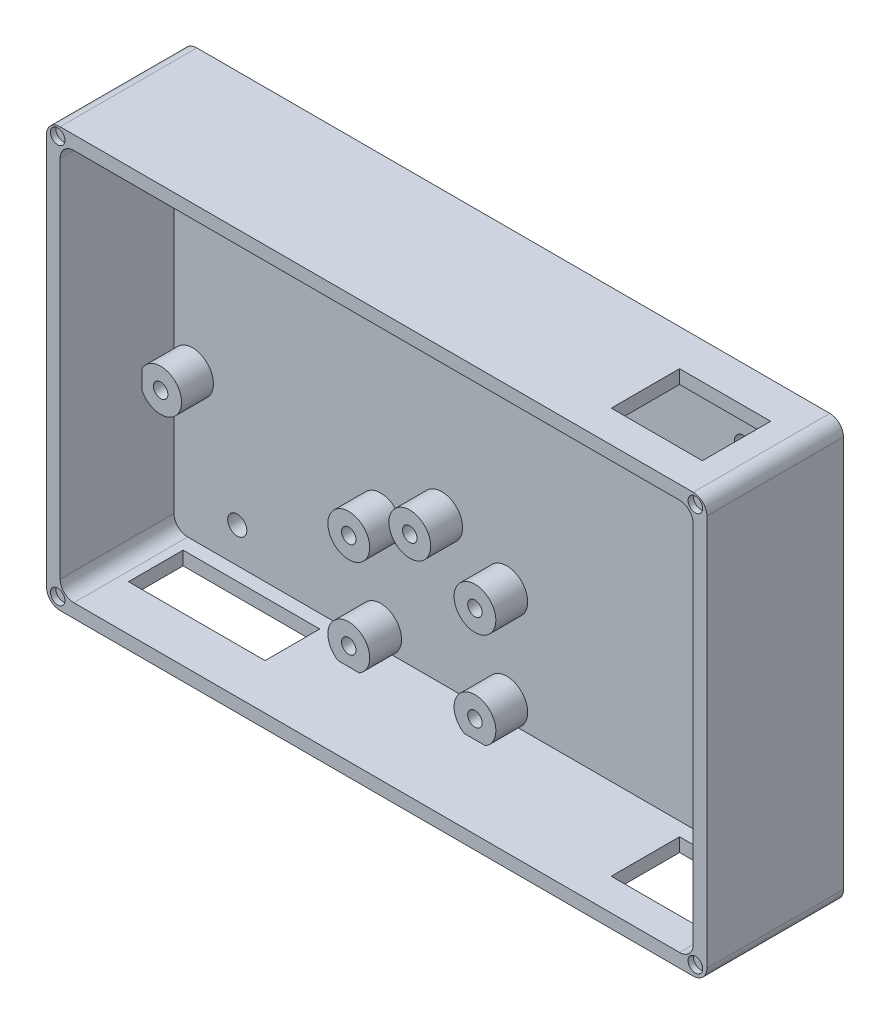
from build123d import *

# Parameters (mm, degrees)
FORMA_DEPTH           = 5
MARCO_DEPTH           = 25
CROQUIS5_R            = 4.5875
CROQUIS5_R_2          = 1.5875
BASEPCB_DEPTH         = 7
SUJECI_NREL_DEPTH     = 7
CROQUIS8_R            = 2.1
BARRENOSMURO_DEPTH    = 14
CROQUIS10_R           = 1.6
CORTAR_EXTRUIR2_DEPTH = 1.2
CROQUIS11_W           = 30
CROQUIS11_H           = 12
CORTAR_EXTRUIR3_DEPTH = 15
CROQUIS12_W           = 20
CROQUIS12_H           = 15
CORTAR_EXTRUIR4_DEPTH = 101.1


with BuildPart() as part:
    # Croquis1 → Forma (new body)
    with BuildSketch(Plane.XY):
        with BuildLine():
            Line((3, 0), (142, 0))
            ThreePointArc((142, 0), (144.121320344, -0.878679656), (145, -3))
            Line((145, -3), (145, -89))
            ThreePointArc((145, -89), (144.121320344, -91.121320344), (142, -92))
            Line((142, -92), (3, -92))
            ThreePointArc((3, -92), (0.878679656, -91.121320344), (0, -89))
            Line((0, -89), (0, -3))
            ThreePointArc((0, -3), (0.878679656, -0.878679656), (3, 0))
        make_face()
    extrude(amount=FORMA_DEPTH)

    # Croquis4 → Marco (add)
    with BuildSketch(Plane.XY.offset(5)):
        with BuildLine():
            Line((3, 0), (142, 0))
            ThreePointArc((142, 0), (144.121320344, -0.878679656), (145, -3))
            Line((145, -3), (145, -89))
            ThreePointArc((145, -89), (144.121320344, -91.121320344), (142, -92))
            Line((142, -92), (3, -92))
            ThreePointArc((3, -92), (0.878679656, -91.121320344), (0, -89))
            Line((0, -89), (0, -3))
            ThreePointArc((0, -3), (0.878679656, -0.878679656), (3, 0))
        make_face()
        with BuildLine():
            Line((6, -89), (139, -89))
            ThreePointArc((139, -89), (141.121320344, -88.121320344), (142, -86))
            Line((142, -86), (142, -6))
            ThreePointArc((142, -6), (141.121320344, -3.878679656), (139, -3))
            Line((139, -3), (6, -3))
            ThreePointArc((6, -3), (3.878679656, -3.878679656), (3, -6))
            Line((3, -6), (3, -86))
            ThreePointArc((3, -86), (3.878679656, -88.121320344), (6, -89))
        make_face(mode=Mode.SUBTRACT)
    extrude(amount=MARCO_DEPTH)

    # Croquis5 → BasePCB (add)
    with BuildSketch(Plane.XY.offset(5)):
        with Locations((7.071067812, -7.071067812)):
            Circle(CROQUIS5_R)
        with Locations((7.071067812, -7.071067812)):
            Circle(CROQUIS5_R_2, mode=Mode.SUBTRACT)
        with Locations((61.771067812, -7.071067812)):
            Circle(CROQUIS5_R)
        with Locations((61.771067812, -7.071067812)):
            Circle(CROQUIS5_R_2, mode=Mode.SUBTRACT)
        with Locations((7.071067812, -57.071067812)):
            Circle(CROQUIS5_R)
        with Locations((7.071067812, -57.071067812)):
            Circle(CROQUIS5_R_2, mode=Mode.SUBTRACT)
        with Locations((61.771067812, -57.071067812)):
            Circle(CROQUIS5_R)
        with Locations((61.771067812, -57.071067812)):
            Circle(CROQUIS5_R_2, mode=Mode.SUBTRACT)
    extrude(amount=BASEPCB_DEPTH)

    # Croquis6 → SujeciónRelé (add)
    with BuildSketch(Plane.XY.offset(5)):
        with BuildLine():
            ThreePointArc((48.374217424, -65.621566311), (47.251685408, -62.911534295), (49.961717424, -64.034066311))
            Line((49.961717424, -64.034066311), (52.961717424, -64.034066311))
            ThreePointArc((52.961717424, -64.034066311), (45.130365065, -60.790213952), (48.374217424, -68.621566311))
            Line((48.374217424, -68.621566311), (48.374217424, -65.621566311))
        make_face()
        with BuildLine():
            Line((52.961717424, -64.034066311), (49.961717424, -64.034066311))
            ThreePointArc((49.961717424, -64.034066311), (49.496749439, -65.156598326), (48.374217424, -65.621566311))
            Line((48.374217424, -65.621566311), (48.374217424, -68.621566311))
            ThreePointArc((48.374217424, -68.621566311), (51.618069782, -67.277918669), (52.961717424, -64.034066311))
        make_face()
        with BuildLine():
            ThreePointArc((48.374217424, -65.621566311), (47.251685408, -62.911534295), (49.961717424, -64.034066311))
            Line((49.961717424, -64.034066311), (52.961717424, -64.034066311))
            ThreePointArc((52.961717424, -64.034066311), (45.130365065, -60.790213952), (48.374217424, -68.621566311))
            Line((48.374217424, -68.621566311), (48.374217424, -65.621566311))
        make_face()
        with BuildLine():
            Line((52.961717424, -64.034066311), (49.961717424, -64.034066311))
            ThreePointArc((49.961717424, -64.034066311), (49.496749439, -65.156598326), (48.374217424, -65.621566311))
            Line((48.374217424, -65.621566311), (48.374217424, -68.621566311))
            ThreePointArc((48.374217424, -68.621566311), (51.618069782, -67.277918669), (52.961717424, -64.034066311))
        make_face()
        with BuildLine():
            ThreePointArc((80.661717424, -64.034066311), (76.074217424, -59.446566311), (71.486717424, -64.034066311))
            Line((71.486717424, -64.034066311), (74.486717424, -64.034066311))
            ThreePointArc((74.486717424, -64.034066311), (76.074217424, -62.446566311), (77.661717424, -64.034066311))
            ThreePointArc((77.661717424, -64.034066311), (77.123659239, -65.22521203), (75.874217424, -65.608917494))
            Line((75.874217424, -65.608917494), (75.874217424, -68.617204564))
            ThreePointArc((75.874217424, -68.617204564), (79.246571144, -67.347875014), (80.661717424, -64.034066311))
        make_face()
        with BuildLine():
            Line((74.486717424, -64.034066311), (71.486717424, -64.034066311))
            ThreePointArc((71.486717424, -64.034066311), (72.76040872, -67.206420031), (75.874217424, -68.617204564))
            Line((75.874217424, -68.617204564), (75.874217424, -65.608917494))
            ThreePointArc((75.874217424, -65.608917494), (74.883071704, -65.083508126), (74.486717424, -64.034066311))
        make_face()
        with BuildLine():
            ThreePointArc((80.661717424, -64.034066311), (76.074217424, -59.446566311), (71.486717424, -64.034066311))
            Line((71.486717424, -64.034066311), (74.486717424, -64.034066311))
            ThreePointArc((74.486717424, -64.034066311), (76.074217424, -62.446566311), (77.661717424, -64.034066311))
            ThreePointArc((77.661717424, -64.034066311), (77.123659239, -65.22521203), (75.874217424, -65.608917494))
            Line((75.874217424, -65.608917494), (75.874217424, -68.617204564))
            ThreePointArc((75.874217424, -68.617204564), (79.246571144, -67.347875014), (80.661717424, -64.034066311))
        make_face()
        with BuildLine():
            Line((74.486717424, -64.034066311), (71.486717424, -64.034066311))
            ThreePointArc((71.486717424, -64.034066311), (72.76040872, -67.206420031), (75.874217424, -68.617204564))
            Line((75.874217424, -68.617204564), (75.874217424, -65.608917494))
            ThreePointArc((75.874217424, -65.608917494), (74.883071704, -65.083508126), (74.486717424, -64.034066311))
        make_face()
        with BuildLine():
            ThreePointArc((80.661717424, -85.034066311), (79.246571144, -81.720257607), (75.874217424, -80.450928057))
            Line((75.874217424, -80.450928057), (75.874217424, -83.459215127))
            ThreePointArc((75.874217424, -83.459215127), (77.123659239, -83.842920591), (77.661717424, -85.034066311))
            ThreePointArc((77.661717424, -85.034066311), (76.074217424, -86.621566311), (74.486717424, -85.034066311))
            Line((74.486717424, -85.034066311), (71.486717424, -85.034066311))
            ThreePointArc((71.486717424, -85.034066311), (72.097860592, -87.321803751), (73.768458065, -89))
            Line((73.768458065, -89), (78.379976782, -89))
            ThreePointArc((78.379976782, -89), (80.050574255, -87.321803751), (80.661717424, -85.034066311))
        make_face()
        with BuildLine():
            Line((75.874217424, -83.459215127), (75.874217424, -80.450928057))
            ThreePointArc((75.874217424, -80.450928057), (72.76040872, -81.86171259), (71.486717424, -85.034066311))
            Line((71.486717424, -85.034066311), (74.486717424, -85.034066311))
            ThreePointArc((74.486717424, -85.034066311), (74.883071704, -83.984624495), (75.874217424, -83.459215127))
        make_face()
        with BuildLine():
            Line((48.374217424, -83.446566311), (48.374217424, -80.446566311))
            ThreePointArc((48.374217424, -80.446566311), (43.944833886, -83.840032088), (46.068458065, -89))
            Line((46.068458065, -89), (50.679976782, -89))
            ThreePointArc((50.679976782, -89), (52.350574255, -87.321803751), (52.961717424, -85.034066311))
            Line((52.961717424, -85.034066311), (49.961717424, -85.034066311))
            ThreePointArc((49.961717424, -85.034066311), (47.251685408, -86.156598326), (48.374217424, -83.446566311))
        make_face()
        with BuildLine():
            ThreePointArc((52.961717424, -85.034066311), (51.618069782, -81.790213952), (48.374217424, -80.446566311))
            Line((48.374217424, -80.446566311), (48.374217424, -83.446566311))
            ThreePointArc((48.374217424, -83.446566311), (49.496749439, -83.911534295), (49.961717424, -85.034066311))
            Line((49.961717424, -85.034066311), (52.961717424, -85.034066311))
        make_face()
    extrude(amount=SUJECI_NREL_DEPTH)

    # Croquis8 → BarrenosMuro (cut)
    with BuildSketch(Plane.XY.offset(5)):
        with Locations((16.887601612, -81.285107943)):
            Circle(CROQUIS8_R)
        with Locations((128.112398388, -10.714892057)):
            Circle(CROQUIS8_R)
        with Locations((128.112398388, -81.285107943)):
            Circle(CROQUIS8_R)
    extrude(amount=-BARRENOSMURO_DEPTH, mode=Mode.SUBTRACT)

    # Croquis10 → Cortar-Extruir2 (cut)
    with BuildSketch(Plane.XY.offset(30)):
        with Locations((142.463102129, -89.588745308)):
            Circle(CROQUIS10_R)
        with Locations((2.463102129, -89.588745308)):
            Circle(CROQUIS10_R)
        with Locations((2.463102129, -2.088745308)):
            Circle(CROQUIS10_R)
        with Locations((142.463102129, -2.088745308)):
            Circle(CROQUIS10_R)
    extrude(amount=-CORTAR_EXTRUIR2_DEPTH, mode=Mode.SUBTRACT)

    # Croquis11 → Cortar-Extruir3 (cut)
    with BuildSketch(Plane.XZ.offset(92)):
        with Locations((23, 14)):
            Rectangle(CROQUIS11_W, CROQUIS11_H)
    extrude(amount=-CORTAR_EXTRUIR3_DEPTH, mode=Mode.SUBTRACT)

    # Croquis12 → Cortar-Extruir4 (cut)
    with BuildSketch(Plane.XZ.offset(92)):
        with Locations((127, 15.5)):
            Rectangle(CROQUIS12_W, CROQUIS12_H)
    extrude(amount=-CORTAR_EXTRUIR4_DEPTH, mode=Mode.SUBTRACT)


solid = part.part
